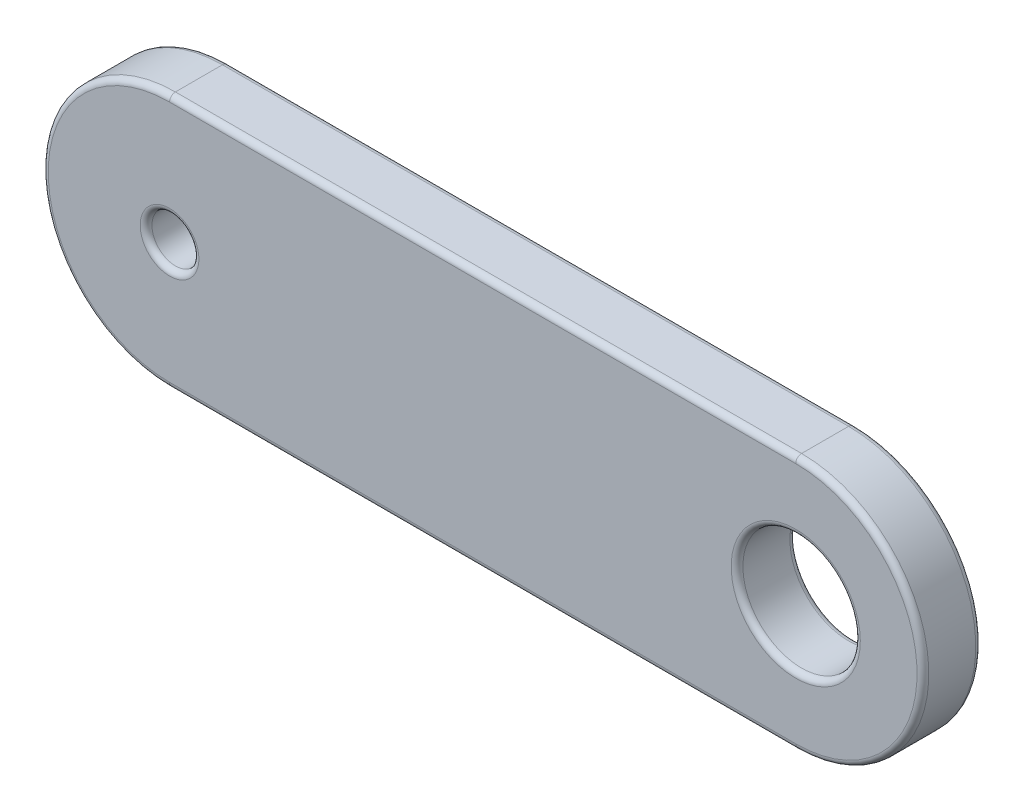
from build123d import *

# Parameters (mm, degrees)
SZKIC1_R                    = 0.6
SZKIC1_R_2                  = 1.5
DODANIE_WYCI_GNI_CIE1_DEPTH = 0.75
ZAOKR_GLENIE1_R             = 0.15


with BuildPart() as part:
    # Szkic1 → Dodanie-wyciągnięcie1 (new body, symmetric)
    with BuildSketch(Plane.XY):
        with BuildLine():
            Line((-8, 3.25), (8, 3.25))
            ThreePointArc((8, 3.25), (11.25, 0), (8, -3.25))
            Line((8, -3.25), (-8, -3.25))
            ThreePointArc((-8, -3.25), (-11.25, 0), (-8, 3.25))
        make_face()
        with Locations((-8, 0)):
            Circle(SZKIC1_R, mode=Mode.SUBTRACT)
        with Locations((8, 0)):
            Circle(SZKIC1_R_2, mode=Mode.SUBTRACT)
    extrude(amount=DODANIE_WYCI_GNI_CIE1_DEPTH, both=True)

    # Zaokrąglenie1
    zaokr_glenie1_edges = [part.edges().sort_by_distance(p)[0] for p in [
        (11.25, 0, 0.75),
        (-8.6, 0, -0.75),
        (-8.6, 0, 0.75),
        (0, 3.25, 0.75),
        (6.5, 0, -0.75),
        (6.5, 0, 0.75),
        (-11.25, 0, 0.75),
        (0, 3.25, -0.75),
        (11.25, 0, -0.75),
        (0, -3.25, -0.75),
        (-11.25, 0, -0.75),
        (0, -3.25, 0.75),
    ]]
    fillet(zaokr_glenie1_edges, radius=ZAOKR_GLENIE1_R)


solid = part.part
